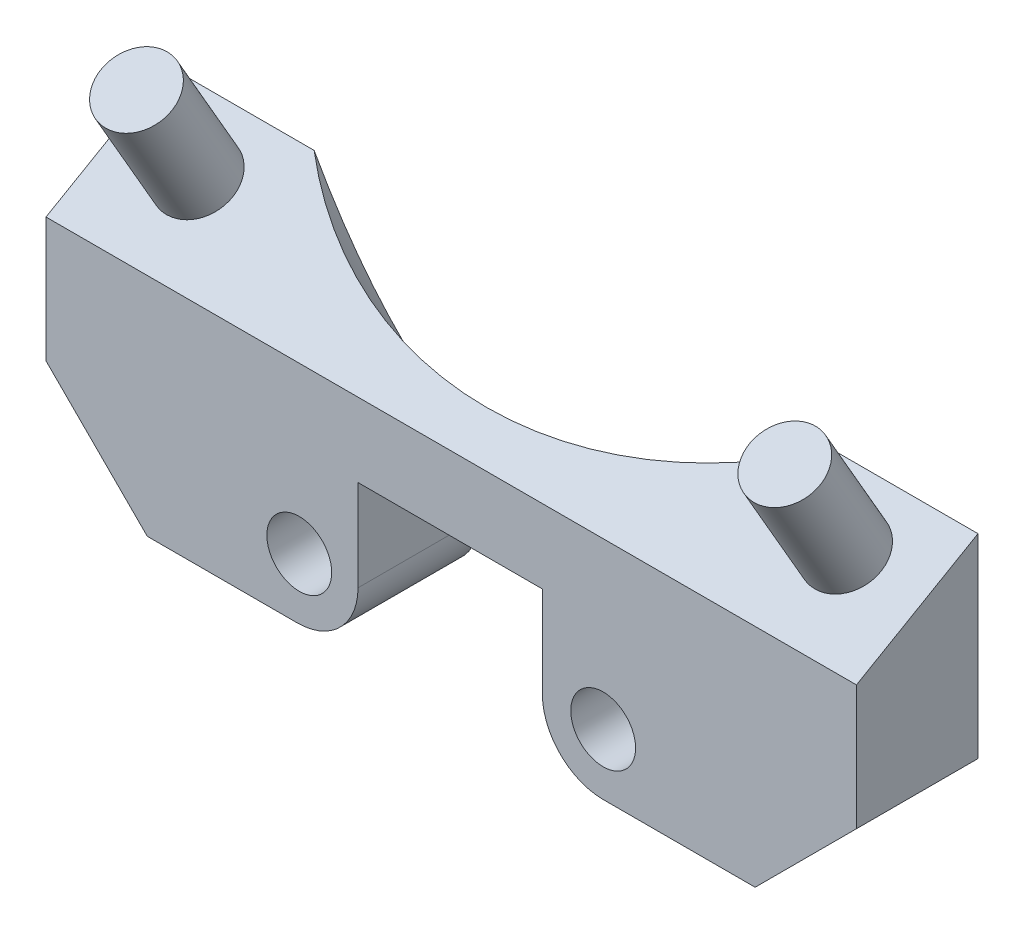
from build123d import *

# Parameters (mm, degrees)
SKETCH3_R           = 1.6
BOSS_EXTRUDE1_DEPTH = 6
BOSS_EXTRUDE3_DEPTH = 40
SKETCH7_R           = 1.75
BOSS_EXTRUDE5_DEPTH = 6
CHAMFER1_SIZE       = 5
FILLET1_R           = 3
SKETCH9_R           = 19
CUT_EXTRUDE1_DEPTH  = 13.656183252


with BuildPart() as part:
    # Sketch3 → Boss-Extrude1 (new body)
    with BuildSketch(Plane.XY):
        Polygon((-42, 0), (-42, -11.15), (-57.5, -11.15), (-57.5, -3.65), (-66.6, -3.65), (-66.6, -11.15), (-82, -11.15), (-82, 0), align=None)
        with Locations((-69.5, -8.15)):
            Circle(SKETCH3_R, mode=Mode.SUBTRACT)
        with Locations((-54.5, -8.15)):
            Circle(SKETCH3_R, mode=Mode.SUBTRACT)
    extrude(amount=BOSS_EXTRUDE1_DEPTH)

    # Sketch5 → Boss-Extrude3 (add)
    with BuildSketch(Plane.ZY.offset(82)):
        Polygon((0, 0), (0, 3.464101615), (6, 0), align=None)
    extrude(amount=-BOSS_EXTRUDE3_DEPTH)

    # Sketch7 → Boss-Extrude5 (add)
    with BuildSketch(Plane(origin=(0, 4.189066469, -1.255675961), x_dir=(-1, 0, 0), z_dir=(0, 0.866025404, 0.5))):
        with Locations((78, 4.378132938)):
            Circle(SKETCH7_R)
    boss_extrude5 = extrude(amount=BOSS_EXTRUDE5_DEPTH)

    # Mirror2: Boss-Extrude5 across plane
    add(boss_extrude5.mirror(Plane(origin=(-62, 0, 0), x_dir=(0, 0, 1), z_dir=(1, 0, 0))))

    # Chamfer1
    chamfer1_edges = [part.edges().sort_by_distance(p)[0] for p in [
        (-42, -11.15, 3),
        (-82, -11.15, 3),
    ]]
    chamfer(chamfer1_edges, length=CHAMFER1_SIZE)

    # Fillet1
    fillet1_edges = [part.edges().sort_by_distance(p)[0] for p in [
        (-57.5, -11.15, 3),
        (-66.6, -11.15, 3),
    ]]
    fillet(fillet1_edges, radius=FILLET1_R)

    # Sketch9 → Cut-Extrude1 (cut, through all)
    with BuildSketch(Plane(origin=(0, 2.598076211, 1.5), x_dir=(1, 0, 0), z_dir=(0, 0.866025404, 0.5))):
        with Locations((-62, 15.803847577)):
            Circle(SKETCH9_R)
    extrude(amount=-CUT_EXTRUDE1_DEPTH, mode=Mode.SUBTRACT)


solid = part.part
